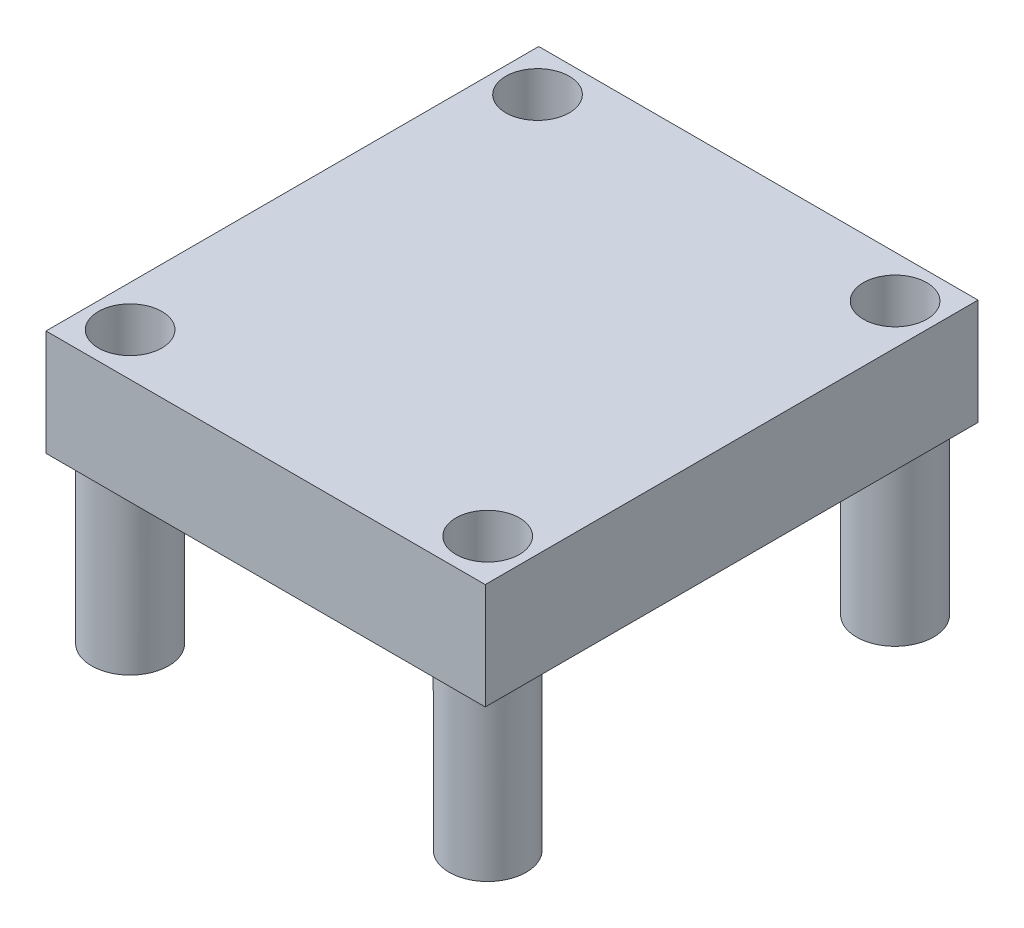
from build123d import *

# Parameters (mm, degrees)
SKETCH1_W               = 22.733
SKETCH1_H               = 25.5016
BOSS_EXTRUDE1_DEPTH     = 5.4864
SKETCH2_R               = 1.9939
SKETCH2_R_2             = 1.642387972
BOSS_EXTRUDE2_DEPTH     = 8.5852
SKETCH5_R               = 1.642387972
CUT_EXTRUDE1_DEPTH      = 1
CUT_EXTRUDE1_DEPTH_BACK = 15.0716


with BuildPart() as part:
    # Sketch1 → Boss-Extrude1 (new body)
    with BuildSketch(Plane(origin=(0, 0, 0), x_dir=(1, 0, 0), z_dir=(0, 1, 0))):
        with Locations((-22.674199551, -11.077689686)):
            Rectangle(SKETCH1_W, SKETCH1_H)
    extrude(amount=BOSS_EXTRUDE1_DEPTH)

    # Sketch2 → Boss-Extrude2 (add)
    with BuildSketch(Plane.XZ):
        with Locations((-31.918497565, 21.596793601)):
            Circle(SKETCH2_R)
        with Locations((-31.918497565, 21.596793601)):
            Circle(SKETCH2_R_2, mode=Mode.SUBTRACT)
        with Locations((-13.414259747, 21.596793601)):
            Circle(SKETCH2_R)
        with Locations((-13.414259747, 21.596793601)):
            Circle(SKETCH2_R_2, mode=Mode.SUBTRACT)
        with Locations((-31.918497565, 0.511660399)):
            Circle(SKETCH2_R)
        with Locations((-31.918497565, 0.511660399)):
            Circle(SKETCH2_R_2, mode=Mode.SUBTRACT)
        with Locations((-13.414259747, 0.511660399)):
            Circle(SKETCH2_R)
        with Locations((-13.414259747, 0.511660399)):
            Circle(SKETCH2_R_2, mode=Mode.SUBTRACT)
    extrude(amount=BOSS_EXTRUDE2_DEPTH)

    # Sketch5 → Cut-Extrude1 (cut, two sides)
    with BuildSketch(Plane(origin=(0, 5.4864, 0), x_dir=(1, 0, 0), z_dir=(0, 1, 0))) as cut_extrude1_sk:
        with Locations((-31.918497565, -0.511660399)):
            Circle(SKETCH5_R)
        with Locations((-13.414259747, -0.511660399)):
            Circle(SKETCH5_R)
        with Locations((-13.414259747, -21.596793601)):
            Circle(SKETCH5_R)
        with Locations((-31.918497565, -21.596793601)):
            Circle(SKETCH5_R)
    extrude(amount=CUT_EXTRUDE1_DEPTH, mode=Mode.SUBTRACT)
    extrude(cut_extrude1_sk.sketch, amount=-CUT_EXTRUDE1_DEPTH_BACK, mode=Mode.SUBTRACT)


solid = part.part
